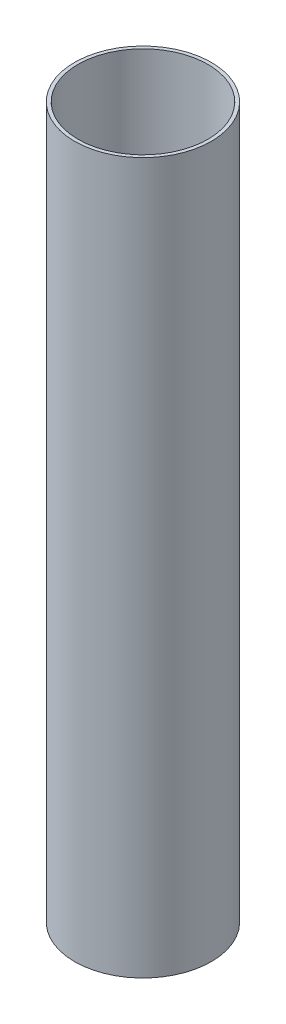
from build123d import *

# Parameters (mm, degrees)
SKETCH1_R           = 34.8996
SKETCH1_R_2         = 33.147
BOSS_EXTRUDE1_DEPTH = 362.585


with BuildPart() as part:
    # Sketch1 → Boss-Extrude1 (new body)
    with BuildSketch(Plane(origin=(0, 0, 0), x_dir=(1, 0, 0), z_dir=(0, 1, 0))):
        Circle(SKETCH1_R)
        Circle(SKETCH1_R_2, mode=Mode.SUBTRACT)
    extrude(amount=BOSS_EXTRUDE1_DEPTH)


solid = part.part
